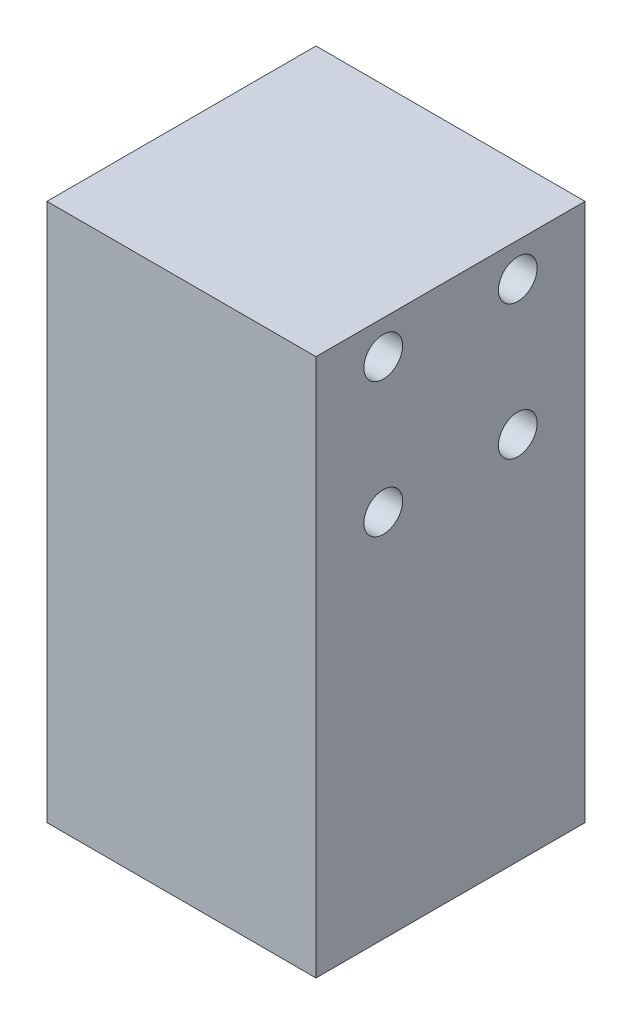
from build123d import *

# Parameters (mm, degrees)
SKETCH1_W           = 25.4
SKETCH1_H           = 25.4
BOSS_EXTRUDE1_DEPTH = 50.8
SKETCH2_R           = 1.8288
CUT_EXTRUDE1_DEPTH  = 12.7
SKETCH3_R           = 1.8288
CUT_EXTRUDE2_DEPTH  = 12.7


with BuildPart() as part:
    # Sketch1 → Boss-Extrude1 (new body)
    with BuildSketch(Plane(origin=(0, 0, 0), x_dir=(1, 0, 0), z_dir=(0, 1, 0))):
        Rectangle(SKETCH1_W, SKETCH1_H)
    extrude(amount=BOSS_EXTRUDE1_DEPTH)

    # Sketch2 → Cut-Extrude1 (cut)
    with BuildSketch(Plane(origin=(12.7, 0, 0), x_dir=(0, 0, -1), z_dir=(1, 0, 0))):
        with Locations((-6.35, 47.625)):
            Circle(SKETCH2_R)
        with Locations((6.35, 47.625)):
            Circle(SKETCH2_R)
        with Locations((6.35, 34.925)):
            Circle(SKETCH2_R)
        with Locations((-6.35, 34.925)):
            Circle(SKETCH2_R)
    extrude(amount=-CUT_EXTRUDE1_DEPTH, mode=Mode.SUBTRACT)

    # Sketch3 → Cut-Extrude2 (cut)
    with BuildSketch(Plane.XZ):
        with Locations((-6.35, 6.35)):
            Circle(SKETCH3_R)
        with Locations((6.35, 6.35)):
            Circle(SKETCH3_R)
        with Locations((6.35, -6.35)):
            Circle(SKETCH3_R)
        with Locations((-6.35, -6.35)):
            Circle(SKETCH3_R)
    extrude(amount=-CUT_EXTRUDE2_DEPTH, mode=Mode.SUBTRACT)


solid = part.part
